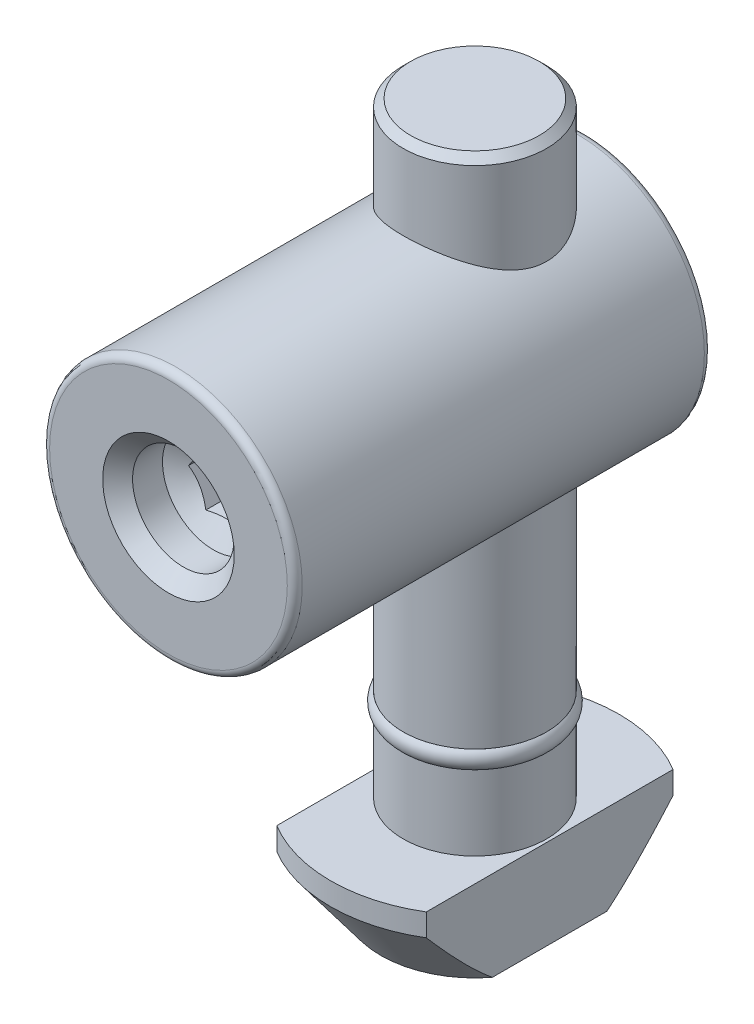
from build123d import *

# Parameters (mm, degrees)
SKETCH_6_OUTSIDE_W          = 32.084
SKETCH_6_OUTSIDE_H          = 32.084
SKETCH_6_OUTSIDE_W_2        = 10
SKETCH_6_OUTSIDE_H_2        = 19.3
CUT_EXTRUDE_1_DEPTH         = 6
CHAMFER_1_SIZE              = 0.5
SKETCH_12_R                 = 8.45
EXTRUDE_2_DEPTH             = 20.5
EXTRUDE_2_DEPTH_BACK        = 7.4
HOLE_WIZARD_M81_D           = 6.8
HOLE_WIZARD_M81_DEPTH       = 3
HOLE_WIZARD_M81_CSINK_D     = 8.8
HOLE_WIZARD_M81_CSINK_ANGLE = 90
HOLE_WIZARD_M81_TIP         = 2.042926105
FILLET_1_R                  = 0.5
CUT_EXTRUDE_2_DEPTH         = 6


with BuildPart() as part:
    # Эскиз3 → Повернуть1 (revolve)
    with BuildSketch(Plane.XY, mode=Mode.PRIVATE) as revolve_1_sk:
        Polygon((0, 0), (-4.8, 0), (-4.8, -34.3), (-4.3, -34.3), (-4.3, -35.5), (-4.8, -35.5), (-4.8, -40.5), (-9.65, -40.5), (-9.65, -42), (-6.3, -46.5), (0, -46.5), align=None)
    revolve(revolve_1_sk.sketch.rotate(Axis((0, 0, 0), (0, 1, 0)), 270), axis=Axis((0, 0, 0), (0, 1, 0)))  # turned: the seam where the file's is

    # Эскиз6 outside → Вырез-Вытянуть1 (cut)
    with BuildSketch(Plane.XZ.offset(46.5)):
        Rectangle(SKETCH_6_OUTSIDE_W, SKETCH_6_OUTSIDE_H)
        Rectangle(SKETCH_6_OUTSIDE_W_2, SKETCH_6_OUTSIDE_H_2, mode=Mode.SUBTRACT)
    extrude(amount=-CUT_EXTRUDE_1_DEPTH, mode=Mode.SUBTRACT)

    # Фаска1
    chamfer_1_edges = [part.edges().sort_by_distance(p)[0] for p in [
        (0, 0, 4.8),
    ]]
    chamfer(chamfer_1_edges, length=CHAMFER_1_SIZE)

    # Эскиз12 → Бобышка-Вытянуть2 (add, two sides)
    with BuildSketch(Plane.XY) as extrude_2_sk:
        with Locations((0, -14)):
            Circle(SKETCH_12_R)
    extrude(amount=EXTRUDE_2_DEPTH)
    extrude(extrude_2_sk.sketch, amount=-EXTRUDE_2_DEPTH_BACK)

    # Отверстие обработанное метчиком M81
    with Locations(Plane.XY.offset(20.5)):
        with Locations((0, -14)):
            CounterSinkHole(HOLE_WIZARD_M81_D / 2, HOLE_WIZARD_M81_CSINK_D / 2, depth=HOLE_WIZARD_M81_DEPTH, counter_sink_angle=HOLE_WIZARD_M81_CSINK_ANGLE)
            with Locations((0, 0, -(HOLE_WIZARD_M81_DEPTH + HOLE_WIZARD_M81_TIP / 2))):  # 118° drill point
                Cone(0, HOLE_WIZARD_M81_D / 2, HOLE_WIZARD_M81_TIP, mode=Mode.SUBTRACT)

    # Скругление1
    fillet_1_edges = [part.edges().sort_by_distance(p)[0] for p in [
        (-8.45, -14, -7.4),
        (-8.45, -14, 20.5),
    ]]
    fillet(fillet_1_edges, radius=FILLET_1_R)

    # Эскиз15 → Вырез-Вытянуть2 (cut)
    with BuildSketch(Plane.XY.offset(20.5)):
        Polygon((2.309401077, -14), (1.154700538, -12), (-1.154700538, -12), (-2.309401077, -14), (-1.154700538, -16), (1.154700538, -16), align=None)
    extrude(amount=-CUT_EXTRUDE_2_DEPTH, mode=Mode.SUBTRACT)


with BuildPart() as body_2:
    # Эскиз16 → Повернуть2 (revolve)
    with BuildSketch(Plane.XY, mode=Mode.PRIVATE) as revolve_2_sk:
        with BuildLine():
            Line((-4.3, -34.3), (-4.8, -34.3))
            ThreePointArc((-4.8, -34.3), (-5.081024968, -34.9), (-4.8, -35.5))
            Line((-4.8, -35.5), (-4.3, -35.5))
            Line((-4.3, -35.5), (-4.3, -34.3))
        make_face()
    revolve(revolve_2_sk.sketch.rotate(Axis((0, -34.3, 0), (0, -1, 0)), 90), axis=Axis((0, -34.3, 0), (0, -1, 0)))  # turned: the seam where the file's is


solid = Compound([part.part, body_2.part])
